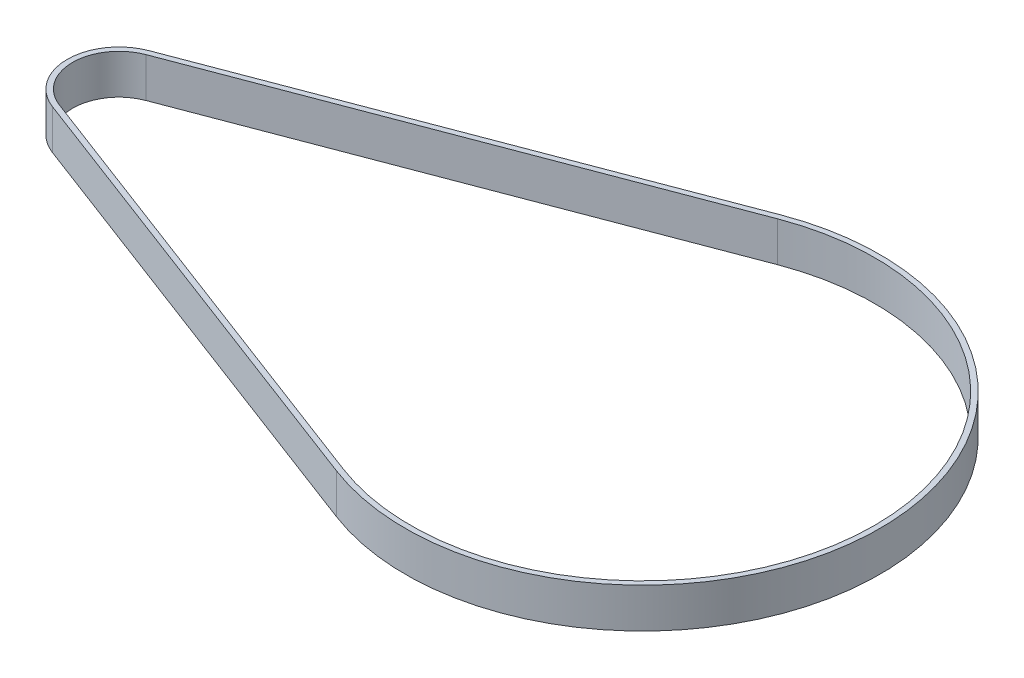
from build123d import *

# Parameters (mm, degrees)
BOSS_EXTRUDE1_DEPTH = 6


with BuildPart() as part:
    # Sketch1 → Boss-Extrude1 (new body)
    with BuildSketch(Plane(origin=(0, 0, 0), x_dir=(1, 0, 0), z_dir=(0, 1, 0))):
        with BuildLine():
            Line((-81.764556962, 7.293642766), (-12.688607595, 33.475950133))
            ThreePointArc((-12.688607595, 33.475950133), (35.8, 0), (-12.688607595, -33.475950133))
            Line((-12.688607595, -33.475950133), (-81.764556962, -7.293642766))
            ThreePointArc((-81.764556962, -7.293642766), (-86.8, 0), (-81.764556962, 7.293642766))
        make_face()
        with BuildLine():
            Line((-81.481012658, 6.545576842), (-12.405063291, 32.727884208))
            ThreePointArc((-12.405063291, 32.727884208), (35, 0), (-12.405063291, -32.727884208))
            Line((-12.405063291, -32.727884208), (-81.481012658, -6.545576842))
            ThreePointArc((-81.481012658, -6.545576842), (-86, 0), (-81.481012658, 6.545576842))
        make_face(mode=Mode.SUBTRACT)
    extrude(amount=BOSS_EXTRUDE1_DEPTH)


solid = part.part
